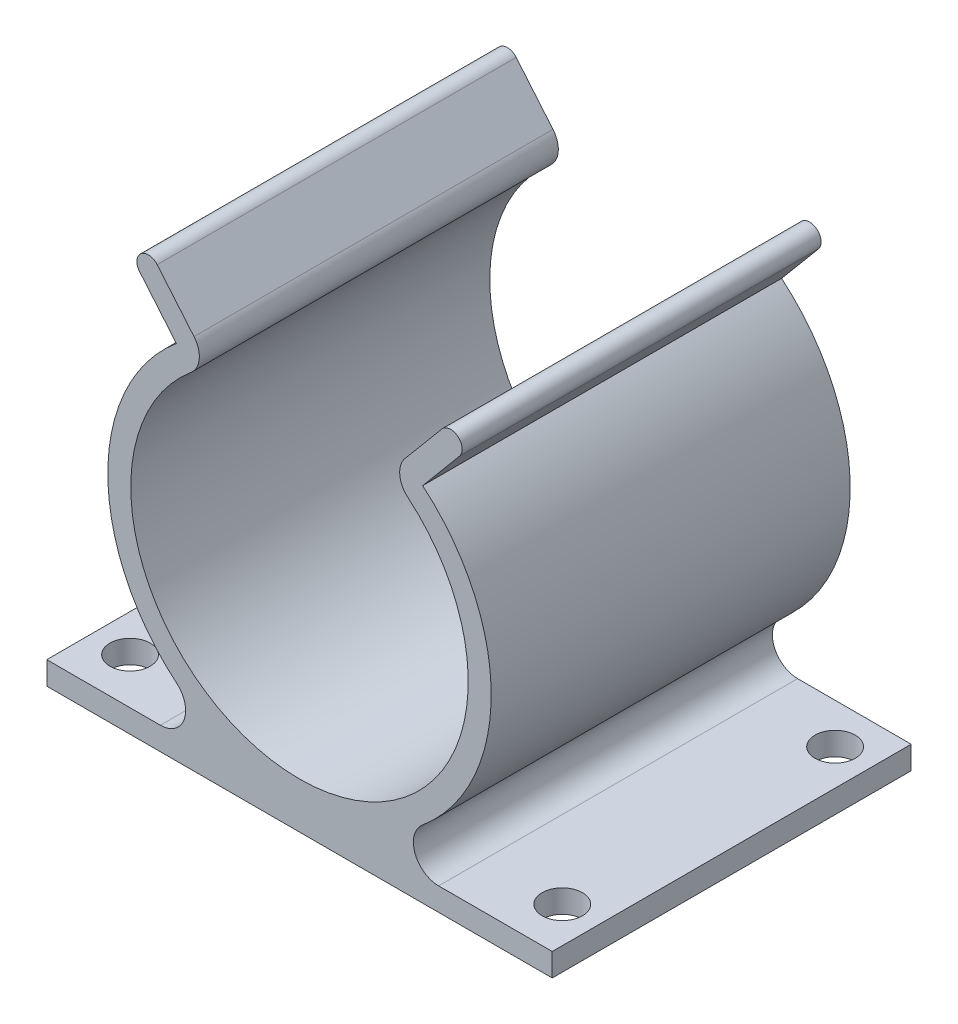
from build123d import *

# Parameters (mm, degrees)
BOSS_EXTRUDE1_DEPTH = 25
CUT_EXTRUDE1_REACH  = 31.553
SKETCH3_R           = 1.4


with BuildPart() as part:
    # Sketch1 → Boss-Extrude1 (new body)
    with BuildSketch(Plane.XY):
        with BuildLine():
            Line((-17.6, 0.8), (-9.688838924, 0.8))
            ThreePointArc((-9.688838924, 0.8), (-8.036343261, 1.958278485), (-8.561462594, 3.906765244))
            ThreePointArc((-8.561462594, 3.906765244), (-13.349996928, 14.140943968), (-8.575351799, 24.381609919))
            Line((-8.575351799, 24.381609919), (-11.137608501, 27.438745265))
            ThreePointArc((-11.137608501, 27.438745265), (-11.038357078, 28.565754207), (-9.911348137, 28.466502784))
            Line((-9.911348137, 28.466502784), (-7.349091434, 25.409367438))
            ThreePointArc((-7.349091434, 25.409367438), (-6.981520468, 24.24124721), (-7.54759428, 23.155349554))
            ThreePointArc((-7.54759428, 23.155349554), (0, 2.4), (7.54759428, 23.155349554))
            ThreePointArc((7.54759428, 23.155349554), (6.981520468, 24.24124721), (7.349091434, 25.409367438))
            Line((7.349091434, 25.409367438), (9.911348137, 28.466502784))
            ThreePointArc((9.911348137, 28.466502784), (11.038357078, 28.565754207), (11.137608501, 27.438745265))
            Line((11.137608501, 27.438745265), (8.575351799, 24.381609919))
            ThreePointArc((8.575351799, 24.381609919), (13.349996928, 14.140943968), (8.561462594, 3.906765244))
            ThreePointArc((8.561462594, 3.906765244), (8.036343261, 1.958278485), (9.688838924, 0.8))
            Line((9.688838924, 0.8), (17.6, 0.8))
            Line((17.6, 0.8), (17.6, -0.8))
            Line((17.6, -0.8), (-17.6, -0.8))
            Line((-17.6, -0.8), (-17.6, 0.8))
        make_face()
    extrude(amount=BOSS_EXTRUDE1_DEPTH)

    # Sketch3 → Cut-Extrude1 (cut, up to next)
    with BuildSketch(Plane.XZ.offset(0.8), mode=Mode.PRIVATE) as cut_extrude1_sk1:
        with Locations((-15, 21.8)):
            Circle(SKETCH3_R)
    cut_extrude1_tool1 = extrude(cut_extrude1_sk1.sketch, amount=-CUT_EXTRUDE1_REACH, mode=Mode.PRIVATE) & part.part
    add(cut_extrude1_tool1.solids().sort_by_distance((-15, -0.8, 21.8))[0], mode=Mode.SUBTRACT)
    # Sketch3 → Cut-Extrude1 (cut, up to next)
    with BuildSketch(Plane.XZ.offset(0.8), mode=Mode.PRIVATE) as cut_extrude1_sk2:
        with Locations((15.1, 21.8)):
            Circle(SKETCH3_R)
    cut_extrude1_tool2 = extrude(cut_extrude1_sk2.sketch, amount=-CUT_EXTRUDE1_REACH, mode=Mode.PRIVATE) & part.part
    add(cut_extrude1_tool2.solids().sort_by_distance((15.1, -0.8, 21.8))[0], mode=Mode.SUBTRACT)
    # Sketch3 → Cut-Extrude1 (cut, up to next)
    with BuildSketch(Plane.XZ.offset(0.8), mode=Mode.PRIVATE) as cut_extrude1_sk3:
        with Locations((-15, 2.8)):
            Circle(SKETCH3_R)
    cut_extrude1_tool3 = extrude(cut_extrude1_sk3.sketch, amount=-CUT_EXTRUDE1_REACH, mode=Mode.PRIVATE) & part.part
    add(cut_extrude1_tool3.solids().sort_by_distance((-15, -0.8, 2.8))[0], mode=Mode.SUBTRACT)
    # Sketch3 → Cut-Extrude1 (cut, up to next)
    with BuildSketch(Plane.XZ.offset(0.8), mode=Mode.PRIVATE) as cut_extrude1_sk4:
        with Locations((15.1, 2.8)):
            Circle(SKETCH3_R)
    cut_extrude1_tool4 = extrude(cut_extrude1_sk4.sketch, amount=-CUT_EXTRUDE1_REACH, mode=Mode.PRIVATE) & part.part
    add(cut_extrude1_tool4.solids().sort_by_distance((15.1, -0.8, 2.8))[0], mode=Mode.SUBTRACT)


solid = part.part
